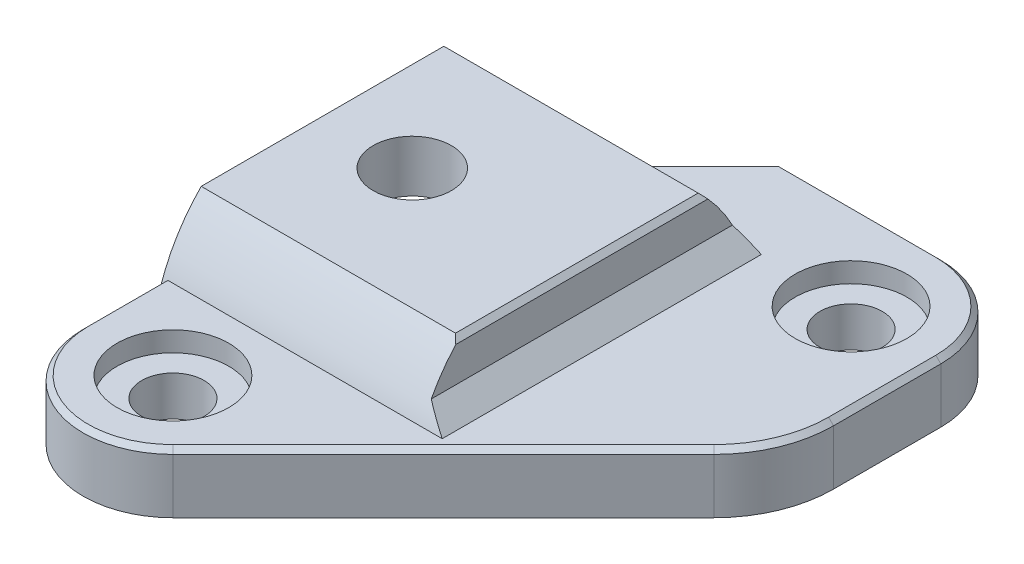
from build123d import *

# Parameters (mm, degrees)
SKETCH1_R           = 1.5625
BOSS_EXTRUDE1_DEPTH = 3
BOSS_EXTRUDE2_DEPTH = 13
CUT_EXTRUDE1_DEPTH  = 11.5
SKETCH4_R           = 1.96
CUT_EXTRUDE2_DEPTH  = 7
CHAMFER1_SIZE       = 1
FILLET1_R           = 6
CHAMFER2_SIZE       = 3.4
CHAMFER3_SIZE       = 0.5
SKETCH5_R           = 2.8
CUT_EXTRUDE3_DEPTH  = 1
SKETCH6_R           = 1.25
SKETCH6_R_2         = 2
BOSS_EXTRUDE3_DEPTH = 1
CHAMFER4_SIZE       = 0.25


with BuildPart() as part:
    # Sketch1 → Boss-Extrude1 (new body)
    with BuildSketch(Plane(origin=(0, 0, 0), x_dir=(1, 0, 0), z_dir=(0, 1, 0))):
        with BuildLine():
            Line((3.181980515, -15.181980515), (18.5, 0.136038969))
            Line((18.5, 0.136038969), (18.5, 8))
            ThreePointArc((18.5, 8), (17.181980515, 11.181980515), (14, 12.5))
            Line((14, 12.5), (6, 12.5))
            Line((6, 12.5), (1, 7.5))
            Line((1, 7.5), (-4.5, 2))
            Line((-4.5, 2), (-4.5, -6.5))
            Line((-4.5, -6.5), (-4.5, -12))
            ThreePointArc((-4.5, -12), (-1.722075446, -16.157457896), (3.181980515, -15.181980515))
        make_face()
        with Locations((0, -12)):
            Circle(SKETCH1_R, mode=Mode.SUBTRACT)
        with Locations((14, 8)):
            Circle(SKETCH1_R, mode=Mode.SUBTRACT)
    extrude(amount=BOSS_EXTRUDE1_DEPTH)

    # Sketch2 → Boss-Extrude2 (add)
    with BuildSketch(Plane.ZY.offset(4.5)):
        with BuildLine():
            Line((-8, 0), (8, 0))
            Line((8, 0), (8, 3))
            ThreePointArc((8, 3), (7.199378454, 4.60097271), (6.08276253, 6))
            Line((6.08276253, 6), (-6.08276253, 6))
            ThreePointArc((-6.08276253, 6), (-7.199378454, 4.60097271), (-8, 3))
            Line((-8, 3), (-8, 0))
        make_face()
    extrude(amount=-BOSS_EXTRUDE2_DEPTH)

    # Sketch3 → Cut-Extrude1 (cut)
    with BuildSketch(Plane.ZY.offset(4.5)):
        with BuildLine():
            Line((-6.75, 0), (6.75, 0))
            ThreePointArc((6.75, 0), (6.516244021, 1.760983776), (5.831166264, 3.4))
            Line((5.831166264, 3.4), (-5.831166264, 3.4))
            ThreePointArc((-5.831166264, 3.4), (-6.516244021, 1.760983776), (-6.75, 0))
        make_face()
    extrude(amount=-CUT_EXTRUDE1_DEPTH, mode=Mode.SUBTRACT)

    # Sketch4 → Cut-Extrude2 (cut, through all)
    with BuildSketch(Plane(origin=(0, 6, 0), x_dir=(1, 0, 0), z_dir=(0, 1, 0))):
        Circle(SKETCH4_R)
    extrude(amount=-CUT_EXTRUDE2_DEPTH, mode=Mode.SUBTRACT)

    # Chamfer1
    chamfer1_edges = [part.edges().sort_by_distance(p)[0] for p in [
        (8.5, 3, 0),
    ]]
    chamfer(chamfer1_edges, length=CHAMFER1_SIZE)

    # Fillet1
    fillet1_edges = [part.edges().sort_by_distance(p)[0] for p in [
        (18.5, 1.5, -0.136038969),
    ]]
    fillet(fillet1_edges, radius=FILLET1_R)

    # Chamfer2
    chamfer2_edges = [part.edges().sort_by_distance(p)[0] for p in [
        (-4.5, 0, -7.375),
    ]]
    chamfer(chamfer2_edges, length=CHAMFER2_SIZE)

    # Chamfer3
    chamfer3_edges = [part.edges().sort_by_distance(p)[0] for p in [
        (7, 1.760983776, -6.516244021),
        (7, 3.4, 0),
        (7, 1.760983776, 6.516244021),
    ]]
    chamfer(chamfer3_edges, length=CHAMFER3_SIZE)

    # Sketch5 → Cut-Extrude3 (cut)
    with BuildSketch(Plane(origin=(0, 3, 0), x_dir=(1, 0, 0), z_dir=(0, 1, 0))):
        with Locations((0, -12)):
            Circle(SKETCH5_R)
        with Locations((14, 8)):
            Circle(SKETCH5_R)
    extrude(amount=-CUT_EXTRUDE3_DEPTH, mode=Mode.SUBTRACT)

    # Sketch6 → Boss-Extrude3 (add)
    with BuildSketch(Plane.XZ):
        with Locations((4.5, 9.75)):
            Circle(SKETCH6_R)
        with Locations((11.5, 0)):
            Circle(SKETCH6_R_2)
        with Locations((7.5, -9.5)):
            Circle(SKETCH6_R)
    extrude(amount=BOSS_EXTRUDE3_DEPTH)

    # Chamfer4
    chamfer4_edges = [part.edges().sort_by_distance(p)[0] for p in [
        (-1.722075446, 3, 16.157457896),
        (3.25, -1, 9.75),
        (9.5, -1, 0),
        (6.25, -1, -9.5),
        (9.962310601, 3, 8.401650429),
        (17.181980515, 3, -11.181980515),
        (10, 3, -12.5),
        (-4.5, 3, 10),
        (3.75, 3, -10.25),
        (8.5, 6, 0),
        (18.5, 3, -5.310660172),
        (18.043277195, 3, -0.325219749),
    ]]
    chamfer(chamfer4_edges, length=CHAMFER4_SIZE)


solid = part.part
